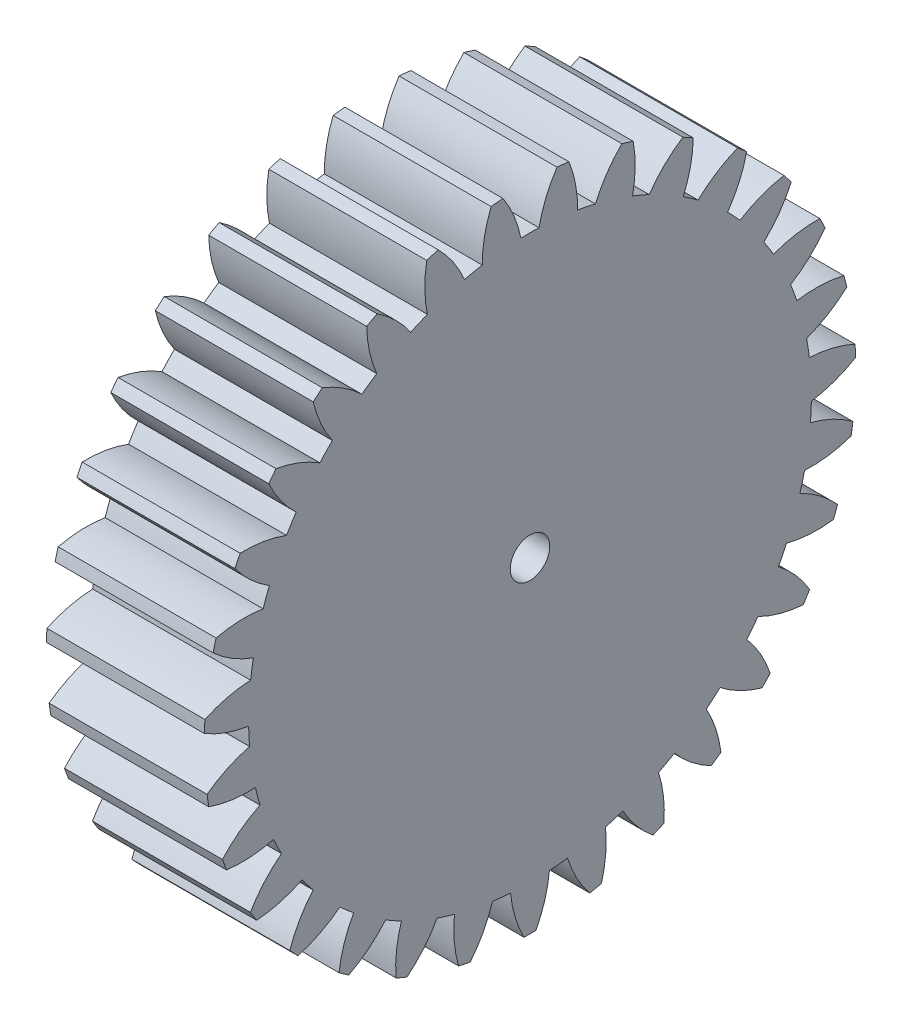
from build123d import *

# Parameters (mm, degrees)
BASPROSKE_W     = 20
BASPROSKE_H     = 41.25
TOOTHCUT_DEPTH  = 62.669481918
TEETHCUTS_COUNT = 31
TEETHCUTS_ANGLE = 348.387096774
BORSKE_R        = 2.5
BORE_DEPTH      = 50.0000508


with BuildPart() as part:
    # BasProSke → Base-Revolve (revolve)
    with BuildSketch(Plane(origin=(0, 0, 0), x_dir=(1, 0, 0), z_dir=(0, 1, 0)), mode=Mode.PRIVATE) as base_revolve_sk:
        with Locations((10, 20.625)):
            Rectangle(BASPROSKE_W, BASPROSKE_H)
    revolve(base_revolve_sk.sketch.rotate(Axis((-10, 0, 0), (1, 0, 0)), 180), axis=Axis((-10, 0, 0), (1, 0, 0)))

    # TooCutSke → ToothCut (cut, through all)
    with BuildSketch(Plane(origin=(0, 0, 0), x_dir=(0, 0, -1), z_dir=(1, 0, 0))):
        with BuildLine():
            ThreePointArc((1.147808078, 35.605503965), (0, 35.624), (-1.147808078, 35.605503965))
            ThreePointArc((-1.147808078, 35.605503965), (-2.025088466, 38.480305856), (-3.440714783, 41.131741112))
            ThreePointArc((-3.440714783, 41.131741112), (0, 41.2754), (3.440714783, 41.131741112))
            ThreePointArc((3.440714783, 41.131741112), (2.025088466, 38.480305856), (1.147808078, 35.605503965))
        make_face()
    toothcut = extrude(amount=TOOTHCUT_DEPTH, mode=Mode.SUBTRACT)

    # TeethCuts: ToothCut ×31 about axis
    teethcuts_axis = Axis((-10, 0, 0), (1, 0, 0))
    for i in range(1, TEETHCUTS_COUNT):
        add(toothcut.rotate(teethcuts_axis, i * TEETHCUTS_ANGLE / (TEETHCUTS_COUNT - 1)), mode=Mode.SUBTRACT)

    # BorSke → Bore (cut, symmetric)
    with BuildSketch(Plane(origin=(0, 0, 0), x_dir=(0, 0, -1), z_dir=(1, 0, 0))):
        with Locations(Location((0, 0, 0), (0, 0, 180))):
            Circle(BORSKE_R)
    extrude(amount=BORE_DEPTH, both=True, mode=Mode.SUBTRACT)


solid = part.part
